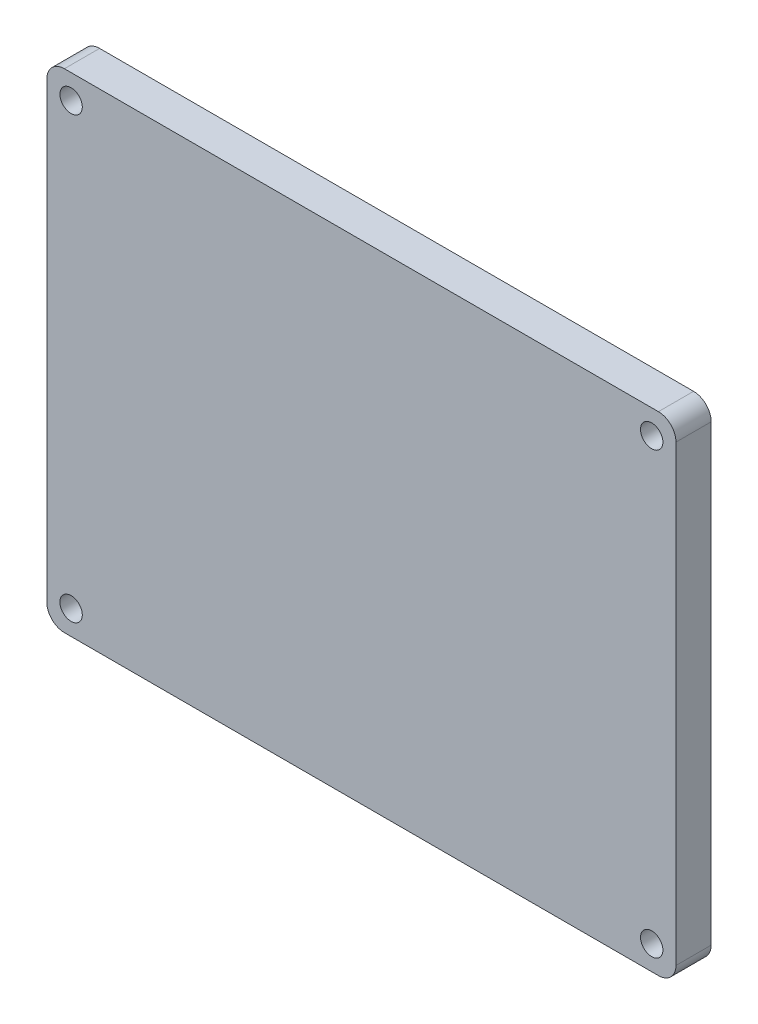
from build123d import *

# Parameters (mm, degrees)
SKETCH1_W                 = 113.538
SKETCH1_H                 = 88.138
EXTRUDE1_DEPTH            = 6.35
F_8_CLEARANCE_HOLE1_D     = 4.0386
F_8_CLEARANCE_HOLE1_DEPTH = 6.35
FILLET2_R                 = 3.175


with BuildPart() as part:
    # Sketch1 → Extrude1 (new body)
    with BuildSketch(Plane.XY):
        Rectangle(SKETCH1_W, SKETCH1_H)
    extrude(amount=EXTRUDE1_DEPTH)

    # #8 Clearance Hole1
    with Locations(Plane(origin=(-52.3875, 39.6875, 6.35), x_dir=(1, 0, 0), z_dir=(0, 0, 1))):
        with Locations((0, 0), (104.775, 0), (104.775, -79.375), (0, -79.375)):
            Hole(F_8_CLEARANCE_HOLE1_D / 2, depth=F_8_CLEARANCE_HOLE1_DEPTH)

    # Fillet2
    fillet2_edges = [part.edges().sort_by_distance(p)[0] for p in [
        (-56.769, 44.069, 3.175),
        (56.769, 44.069, 3.175),
        (56.769, -44.069, 3.175),
        (-56.769, -44.069, 3.175),
    ]]
    fillet(fillet2_edges, radius=FILLET2_R)


solid = part.part
